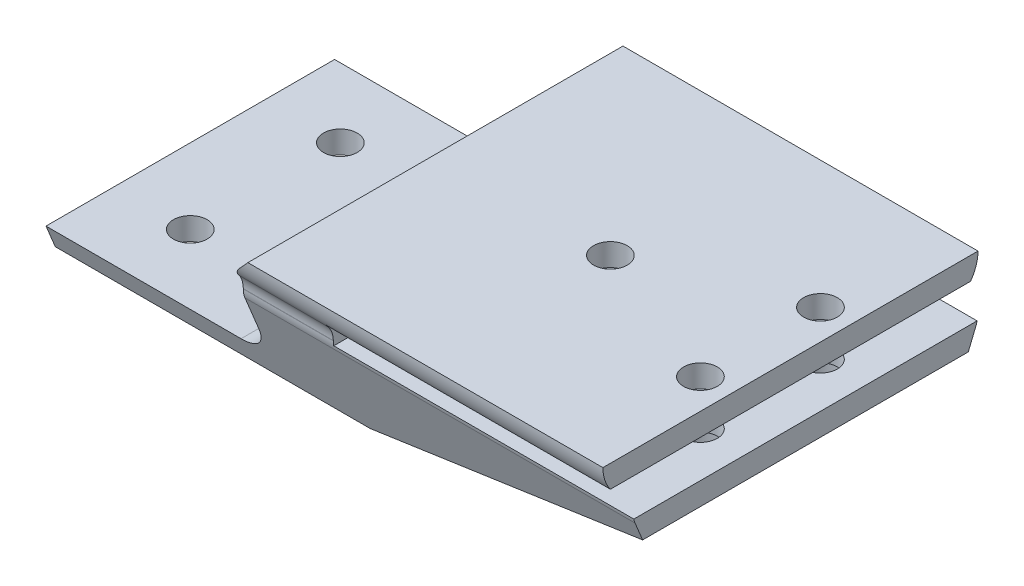
from build123d import *

# Parameters (mm, degrees)
BOSS_EXTRUDE1_DEPTH = 30
CUT_EXTRUDE1_DEPTH  = 82
SKETCH3_R           = 2.25
CUT_EXTRUDE2_DEPTH  = 60
HOLE2_D             = 4.5
HOLE2_CBORE_D       = 6
HOLE2_CBORE_DEPTH   = 10


with BuildPart() as part:
    # Sketch1 → Boss-Extrude1 (new body, symmetric)
    with BuildSketch(Plane.XY):
        with BuildLine():
            Line((17, -28), (17, -21.840329668))
            ThreePointArc((17, -21.840329668), (17.377125597, -19.935327763), (18.451612903, -18.31769585))
            ThreePointArc((18.451612903, -18.31769585), (19.07334688, -17.669392712), (19.672315573, -17))
            Line((19.672315573, -17), (67, -17))
            Line((67, -17), (67, -20))
            Line((67, -20), (29, -20))
            Line((29, -20), (29, -23))
            Line((29, -23), (69, -23))
            Line((69, -23), (69, -26))
            Line((69, -26), (29, -35))
            Line((29, -35), (-13, -35))
            Line((-13, -35), (-13, -32))
            Line((-13, -32), (13, -32))
            ThreePointArc((13, -32), (15.828427125, -30.828427125), (17, -28))
        make_face()
    extrude(amount=BOSS_EXTRUDE1_DEPTH, both=True)

    # Sketch2 → Cut-Extrude1 (cut)
    with BuildSketch(Plane(origin=(69, 0, 0), x_dir=(0, 0, -1), z_dir=(1, 0, 0))):
        with BuildLine():
            Line((-22.937838499, -22.36116349), (-22.937838499, -22.406895186))
            ThreePointArc((-22.937838499, -22.406895186), (-22.880874155, -22.988738058), (-22.712144413, -23.548484732))
            Line((-22.712144413, -23.548484732), (-18, -35))
            Line((-18, -35), (-30, -35))
            Line((-30, -35), (-30, -17))
            Line((-30, -17), (-25, -17))
            ThreePointArc((-25, -17), (-24.666676832, -18.795028508), (-23.711149062, -20.350727181))
            ThreePointArc((-23.711149062, -20.350727181), (-23.1378324, -21.284146385), (-22.937838499, -22.36116349))
        make_face()
        with BuildLine():
            Line((30, -35), (18, -35))
            Line((18, -35), (22.712144413, -23.548484732))
            ThreePointArc((22.712144413, -23.548484732), (22.880874155, -22.988738058), (22.937838499, -22.406895186))
            Line((22.937838499, -22.406895186), (22.937838499, -22.36116349))
            ThreePointArc((22.937838499, -22.36116349), (23.1378324, -21.284146385), (23.711149062, -20.350727181))
            ThreePointArc((23.711149062, -20.350727181), (24.666676832, -18.795028508), (25, -17))
            Line((25, -17), (30, -17))
            Line((30, -17), (30, -35))
        make_face()
    extrude(amount=-CUT_EXTRUDE1_DEPTH, mode=Mode.SUBTRACT)

    # Sketch3 → Cut-Extrude2 (cut)
    with BuildSketch(Plane(origin=(0, -35, 0), x_dir=(-1, 0, 0), z_dir=(0, -1, 0))):
        with Locations((3, -10)):
            Circle(SKETCH3_R)
        with Locations((3, 10)):
            Circle(SKETCH3_R)
    extrude(amount=-CUT_EXTRUDE2_DEPTH, mode=Mode.SUBTRACT)

    # Hole2 (through all)
    with Locations(Plane(origin=(0, -35, 0), x_dir=(-1, 0, 0), z_dir=(0, -1, 0))):
        with Locations((-63, 8), (-63, -8), (-43, 0)):
            CounterBoreHole(HOLE2_D / 2, HOLE2_CBORE_D / 2, HOLE2_CBORE_DEPTH)


solid = part.part
